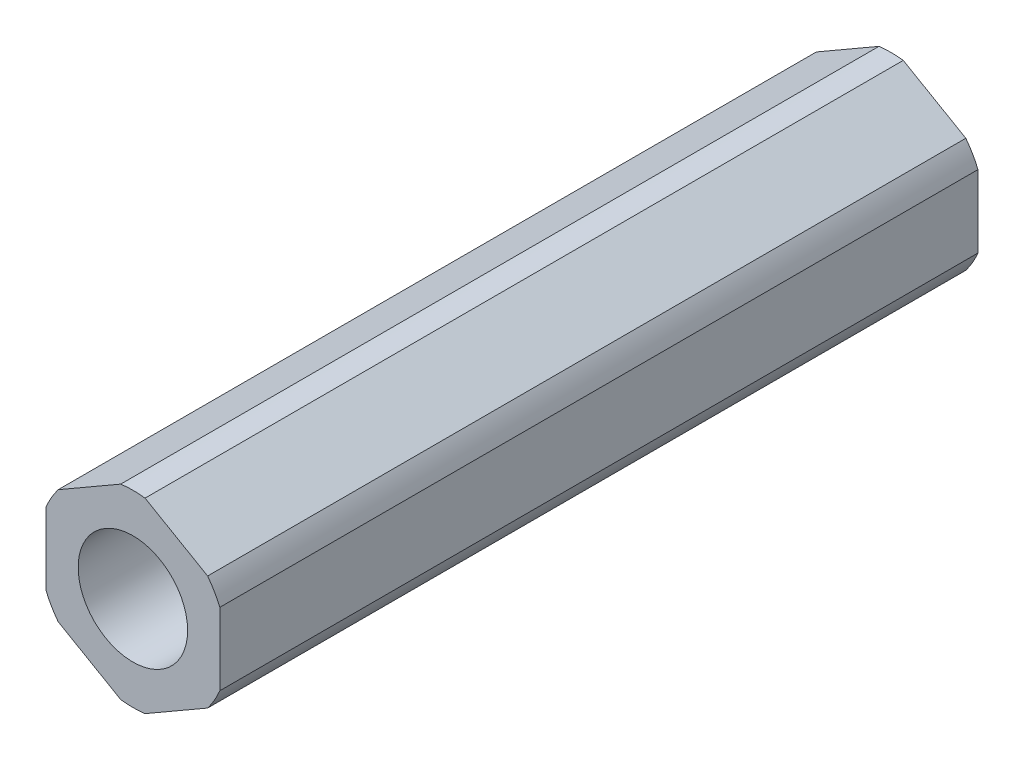
from build123d import *

# Parameters (mm, degrees)
SKETCH1_R               = 6.35
BASIC_ROD_DEPTH         = 27.70251
BASIC_ROD_DEPTH_BACK    = 27.70251
THEX_DEPTH              = 27.70251
SKETCH2_R               = 4
INTERNAL_CUT_DEPTH      = 28.70251
INTERNAL_CUT_DEPTH_BACK = 28.70251


with BuildPart() as part:
    # Sketch1 → Basic Rod (new body, two sides)
    with BuildSketch(Plane.XY) as basic_rod_sk:
        Circle(SKETCH1_R)
    extrude(amount=BASIC_ROD_DEPTH)
    extrude(basic_rod_sk.sketch, amount=-BASIC_ROD_DEPTH_BACK)

    # Sketch8 → THex (add, symmetric)
    with BuildSketch(Plane.XY):
        with BuildLine():
            Line((-0.888411378, 6.819423871), (-5.461588622, 4.179098758))
            ThreePointArc((-5.461588622, 4.179098758), (-5.955700003, 3.438525), (-6.35, 2.640325113))
            Line((-6.35, 2.640325113), (-6.35, -2.640325113))
            ThreePointArc((-6.35, -2.640325113), (-5.955700003, -3.438525), (-5.461588622, -4.179098758))
            Line((-5.461588622, -4.179098758), (-0.888411378, -6.819423871))
            ThreePointArc((-0.888411378, -6.819423871), (0, -6.87705), (0.888411378, -6.819423871))
            Line((0.888411378, -6.819423871), (5.461588622, -4.179098758))
            ThreePointArc((5.461588622, -4.179098758), (5.955700003, -3.438525), (6.35, -2.640325113))
            Line((6.35, -2.640325113), (6.35, 2.640325113))
            ThreePointArc((6.35, 2.640325113), (5.955700003, 3.438525), (5.461588622, 4.179098758))
            Line((5.461588622, 4.179098758), (0.888411378, 6.819423871))
            ThreePointArc((0.888411378, 6.819423871), (0, 6.87705), (-0.888411378, 6.819423871))
        make_face()
    extrude(amount=THEX_DEPTH, both=True)

    # Sketch2 → Internal Cut (cut, two sides)
    with BuildSketch(Plane.XY) as internal_cut_sk:
        Circle(SKETCH2_R)
    extrude(amount=INTERNAL_CUT_DEPTH, mode=Mode.SUBTRACT)
    extrude(internal_cut_sk.sketch, amount=-INTERNAL_CUT_DEPTH_BACK, mode=Mode.SUBTRACT)


solid = part.part
